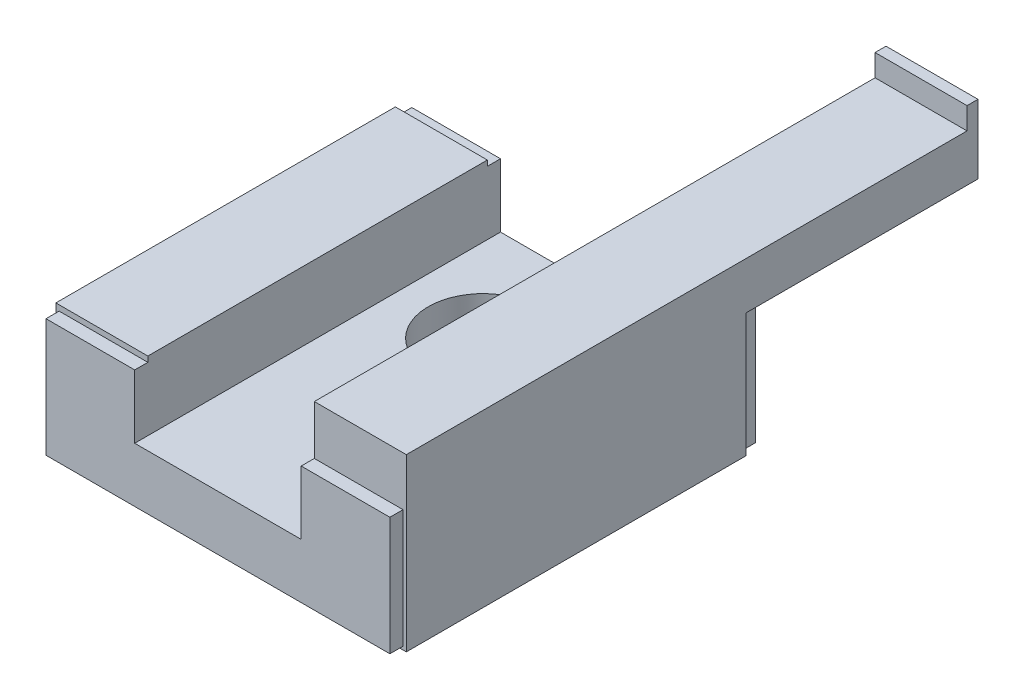
from build123d import *

# Parameters (mm, degrees)
EXTRUDE_1_DEPTH     = 33.4
CUT_EXTRUDE_1_DEPTH = 1.2
CUT_EXTRUDE_2_DEPTH = 1.2
SKETCH_4_W          = 8.4
SKETCH_4_H          = 4.3
EXTRUDE_2_DEPTH     = 21.2
SKETCH_9_R          = 1.5
CUT_EXTRUDE_3_DEPTH = 3.1
SKETCH_10_R         = 5
CUT_EXTRUDE_4_DEPTH = 5.3
SKETCH_11_W         = 8.4
SKETCH_11_H         = 2
EXTRUDE_3_DEPTH     = 1


with BuildPart() as part:
    # 草图1 → 凸台-拉伸1 (new body)
    with BuildSketch(Plane.XY):
        Polygon((-16, 0), (-8, 0), (-7.7, 0.3), (7.7, 0.3), (8, 0), (16, 0), (16, 15.6), (7.6, 15.6), (7.6, 5.3), (-7.6, 5.3), (-7.6, 11.6), (-16, 11.6), align=None)
    extrude(amount=EXTRUDE_1_DEPTH)

    # 草图2 → 切除-拉伸1 (cut)
    with BuildSketch(Plane.XY):
        Polygon((-16, 0), (16, 0), (16, 15.6), (7.6, 15.6), (7.6, 11.6), (15.7, 11.6), (15.7, 0.3), (-15.7, 0.3), (-15.7, 11.1), (-7.6, 11.1), (-7.6, 11.6), (-16, 11.6), align=None)
    extrude(amount=CUT_EXTRUDE_1_DEPTH, mode=Mode.SUBTRACT)

    # 草图3 → 切除-拉伸2 (cut)
    with BuildSketch(Plane.XY.offset(33.4)):
        Polygon((-16, 0), (16, 0), (16, 15.6), (7.6, 15.6), (7.6, 11.1), (15.7, 11.1), (15.7, 0.3), (-15.7, 0.3), (-15.7, 11.1), (-7.6, 11.1), (-7.6, 11.6), (-16, 11.6), align=None)
    extrude(amount=-CUT_EXTRUDE_2_DEPTH, mode=Mode.SUBTRACT)

    # 草图4 → 凸台-拉伸2 (add)
    with BuildSketch(Plane.XY.offset(1.2)):
        with Locations((11.8, 13.45)):
            Rectangle(SKETCH_4_W, SKETCH_4_H)
    extrude(amount=-EXTRUDE_2_DEPTH)

    # 草图5 → 切除-旋转1 (revolve, cut)
    with BuildSketch(Plane.XY.offset(8.7)):
        Polygon((12, 4), (13.621, 4), (13.621, 0.379), (14, 0), (12, 0), align=None)
    revolve(axis=Axis((12, 0, 8.7), (0, 1, 0)), mode=Mode.SUBTRACT)

    # 草图6 → 切除-旋转2 (revolve, cut)
    with BuildSketch(Plane.XY.offset(8.7)):
        Polygon((-12, 4), (-10.379, 4), (-10.379, 0.379), (-10, 0), (-12, 0), align=None)
    revolve(axis=Axis((-12, 0, 8.7), (0, 1, 0)), mode=Mode.SUBTRACT)

    # 草图7 → 切除-旋转3 (revolve, cut)
    with BuildSketch(Plane.XY.offset(24.7)):
        Polygon((12, 4), (13.621, 4), (13.621, 0.379), (14, 0), (12, 0), align=None)
    revolve(axis=Axis((12, 0, 24.7), (0, 1, 0)), mode=Mode.SUBTRACT)

    # 草图8 → 切除-旋转4 (revolve, cut)
    with BuildSketch(Plane.XY.offset(24.7)):
        Polygon((-12, 4), (-10.379, 4), (-10.379, 0.379), (-10, 0), (-12, 0), align=None)
    revolve(axis=Axis((-12, 0, 24.7), (0, 1, 0)), mode=Mode.SUBTRACT)

    # 草图9 → 切除-拉伸3 (cut)
    with BuildSketch(Plane(origin=(0, 0.2, 0), x_dir=(1, 0, 0), z_dir=(0, 1, 0))):
        with Locations((0, -24.7)):
            Circle(SKETCH_9_R)
    extrude(amount=CUT_EXTRUDE_3_DEPTH, mode=Mode.SUBTRACT)

    # 草图10 → 切除-拉伸4 (cut)
    with BuildSketch(Plane(origin=(0, 0.2, 0), x_dir=(1, 0, 0), z_dir=(0, 1, 0))):
        with Locations((0, -9.2)):
            Circle(SKETCH_10_R)
    extrude(amount=CUT_EXTRUDE_4_DEPTH, mode=Mode.SUBTRACT)

    # 草图11 → 凸台-拉伸3 (add)
    with BuildSketch(Plane.XY.offset(-20)):
        with Locations((11.8, 16.6)):
            Rectangle(SKETCH_11_W, SKETCH_11_H)
    extrude(amount=EXTRUDE_3_DEPTH)


solid = part.part
